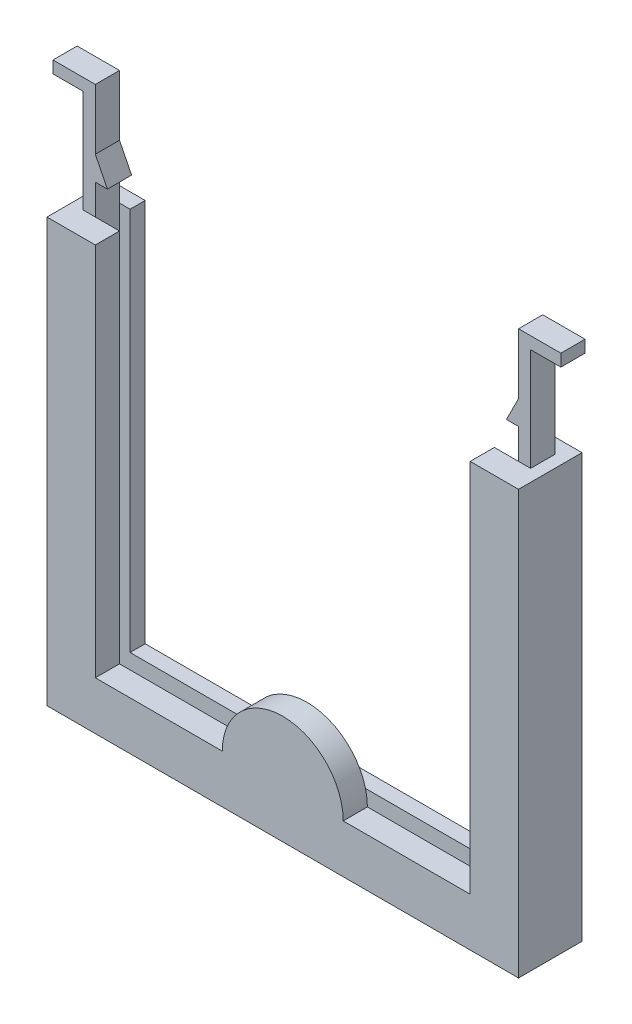
from build123d import *

# Parameters (mm, degrees)
BOSS_EXTRU_1_DEPTH = 6.5
BOSS_EXTRU_2_DEPTH = 2.5
ESQUISSE3_W        = 2
ESQUISSE3_H        = 4
BOSS_EXTRU_3_DEPTH = 9
BOSS_EXTRU_4_START = -4
BOSS_EXTRU_4_DEPTH = 4
BOSS_EXTRU_5_DEPTH = 4
ESQUISSE6_W        = 2
ESQUISSE6_H        = 4
BOSS_EXTRU_6_DEPTH = 10
ESQUISSE7_W        = 4
ESQUISSE7_H        = 2
BOSS_EXTRU_7_DEPTH = 5
ESQUISSE8_W        = 4
ESQUISSE8_H        = 2
BOSS_EXTRU_8_DEPTH = 5
BOSS_EXTRU_9_START = -4
BOSS_EXTRU_9_DEPTH = 4


with BuildPart() as part:
    # Esquisse1 → Boss.-Extru.1 (new body)
    with BuildSketch(Plane.XY):
        Polygon((-74, 4), (-74, 70), (-78, 70), (-78, 0), (0, 0), (0, 70), (-4, 70), (-4, 4), align=None)
    extrude(amount=BOSS_EXTRU_1_DEPTH)

    # Esquisse2 → Boss.-Extru.2 (add)
    with BuildSketch(Plane(origin=(0, 0, 0), x_dir=(-1, 0, 0), z_dir=(0, 0, -1))):
        Polygon((0, 70), (5.75, 70), (5.75, 6.5), (72.25, 6.5), (72.25, 70), (78, 70), (78, 0), (0, 0), align=None)
    extrude(amount=-BOSS_EXTRU_2_DEPTH)

    # Esquisse3 → Boss.-Extru.3 (add)
    with BuildSketch(Plane(origin=(0, 70, 0), x_dir=(1, 0, 0), z_dir=(0, 1, 0))):
        with Locations((-75, -4.5)):
            Rectangle(ESQUISSE3_W, ESQUISSE3_H)
        with Locations((-3, -4.5)):
            Rectangle(ESQUISSE3_W, ESQUISSE3_H)
    extrude(amount=BOSS_EXTRU_3_DEPTH)

    # Esquisse4 → Boss.-Extru.4 (add)
    with BuildSketch(Plane.XY.offset(6.5).offset(BOSS_EXTRU_4_START)):
        Polygon((-4, 79), (-6, 75), (-4, 75), align=None)
        Polygon((-74, 79), (-72, 75), (-74, 75), align=None)
    extrude(amount=BOSS_EXTRU_4_DEPTH)

    # Esquisse5 → Boss.-Extru.5 (add)
    with BuildSketch(Plane.XY.offset(6.5)):
        Polygon((0, 70), (0, 0), (-78, 0), (-78, 70), (-70, 70), (-70, 8), (-8, 8), (-8, 70), align=None)
    extrude(amount=BOSS_EXTRU_5_DEPTH)

    # Esquisse6 → Boss.-Extru.6 (add)
    with BuildSketch(Plane(origin=(0, 79, 0), x_dir=(1, 0, 0), z_dir=(0, 1, 0))):
        with Locations((-3, -4.5)):
            Rectangle(ESQUISSE6_W, ESQUISSE6_H)
        with Locations((-75, -4.5)):
            Rectangle(ESQUISSE6_W, ESQUISSE6_H)
    extrude(amount=BOSS_EXTRU_6_DEPTH)

    # Esquisse7 → Boss.-Extru.7 (add)
    with BuildSketch(Plane(origin=(-2, 0, 0), x_dir=(0, 0, -1), z_dir=(1, 0, 0))):
        with Locations((-4.5, 88)):
            Rectangle(ESQUISSE7_W, ESQUISSE7_H)
    extrude(amount=BOSS_EXTRU_7_DEPTH)

    # Esquisse8 → Boss.-Extru.8 (add)
    with BuildSketch(Plane.ZY.offset(76)):
        with Locations((4.5, 88)):
            Rectangle(ESQUISSE8_W, ESQUISSE8_H)
    extrude(amount=BOSS_EXTRU_8_DEPTH)

    # Esquisse9 → Boss.-Extru.9 (add)
    with BuildSketch(Plane.XY.offset(10.5).offset(BOSS_EXTRU_9_START)):
        with BuildLine():
            Line((-49, 8), (-29, 8))
            ThreePointArc((-29, 8), (-39, 18), (-49, 8))
        make_face()
    extrude(amount=BOSS_EXTRU_9_DEPTH)


solid = part.part
